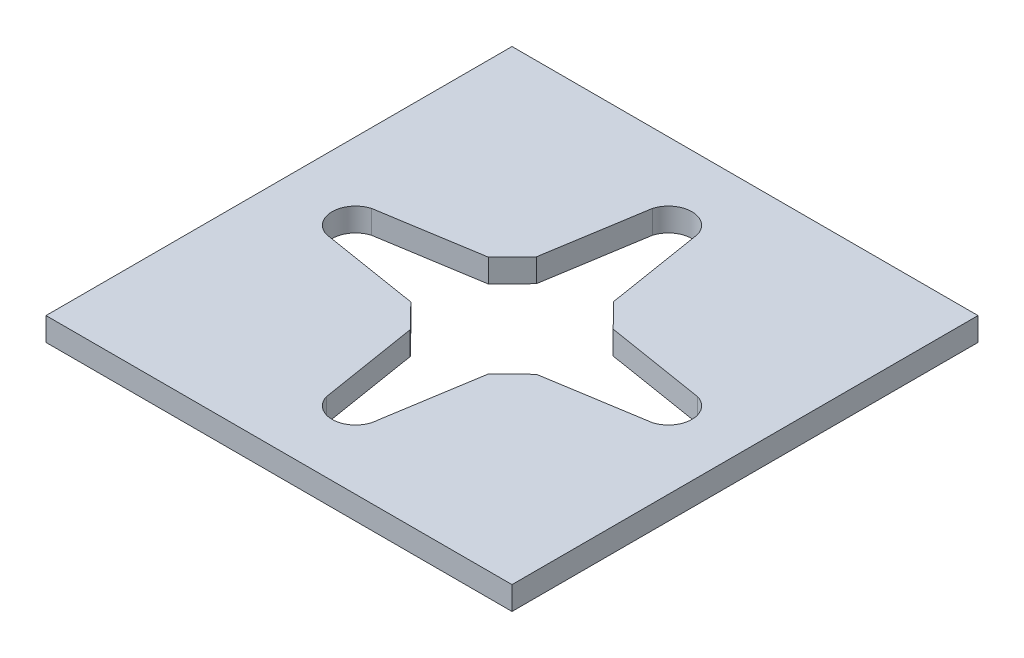
from build123d import *

# Parameters (mm, degrees)
SKETCH1_W           = 50.8
SKETCH1_H           = 50.8
BOSS_EXTRUDE1_DEPTH = 2.54
CUT_EXTRUDE2_DEPTH  = 2.54


with BuildPart() as part:
    # Sketch1 → Boss-Extrude1 (new body)
    with BuildSketch(Plane(origin=(0, 0, 0), x_dir=(1, 0, 0), z_dir=(0, 1, 0))):
        Rectangle(SKETCH1_W, SKETCH1_H)
    extrude(amount=BOSS_EXTRUDE1_DEPTH)

    # Sketch2 → Cut-Extrude2 (cut)
    with BuildSketch(Plane.XZ):
        with BuildLine():
            Line((-4.214616619, 6.877540553), (-6.799823365, 4.227137698))
            Line((-6.799823365, 4.227137698), (-17.756833433, 2.46184495))
            ThreePointArc((-17.756833433, 2.46184495), (-19.612357967, 0), (-17.756833433, -2.46184495))
            Line((-17.756833433, -2.46184495), (-6.799823365, -4.227137698))
            Line((-6.799823365, -4.227137698), (-4.214616619, -6.877540553))
            Line((-4.214616619, -6.877540553), (-2.46184495, -17.756833433))
            ThreePointArc((-2.46184495, -17.756833433), (0, -19.612357967), (2.46184495, -17.756833433))
            Line((2.46184495, -17.756833433), (4.214616619, -6.877540553))
            Line((4.214616619, -6.877540553), (6.799823365, -4.227137698))
            Line((6.799823365, -4.227137698), (17.756833433, -2.46184495))
            ThreePointArc((17.756833433, -2.46184495), (19.612357967, 0), (17.756833433, 2.46184495))
            Line((17.756833433, 2.46184495), (6.877540553, 4.214616619))
            Line((6.877540553, 4.214616619), (4.227137698, 6.799823365))
            Line((4.227137698, 6.799823365), (2.558814736, 17.15495087))
            ThreePointArc((2.558814736, 17.15495087), (2.557405809, 17.185318827), (2.555636489, 17.21566792))
            ThreePointArc((2.555636489, 17.21566792), (0.274616535, 19.597591266), (-2.46184495, 17.756833433))
            Line((-2.46184495, 17.756833433), (-4.214616619, 6.877540553))
        make_face()
    extrude(amount=-CUT_EXTRUDE2_DEPTH, mode=Mode.SUBTRACT)


solid = part.part
